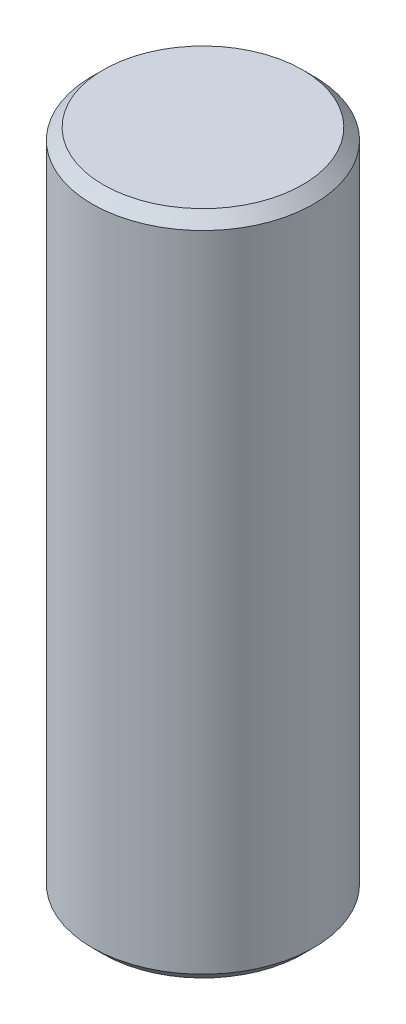
from build123d import *

# Parameters (mm, degrees)
SKETCH1_R           = 2.49
BOSS_EXTRUDE1_DEPTH = 14.98
CHAMFER1_SIZE       = 0.25


with BuildPart() as part:
    # Sketch1 → Boss-Extrude1 (new body)
    with BuildSketch(Plane(origin=(0, 0, 0), x_dir=(1, 0, 0), z_dir=(0, 1, 0))):
        Circle(SKETCH1_R)
    extrude(amount=BOSS_EXTRUDE1_DEPTH)

    # Chamfer1
    chamfer1_edges = [part.edges().sort_by_distance(p)[0] for p in [
        (-2.49, 0, 0),
        (-2.49, 14.98, 0),
    ]]
    chamfer(chamfer1_edges, length=CHAMFER1_SIZE)


solid = part.part
